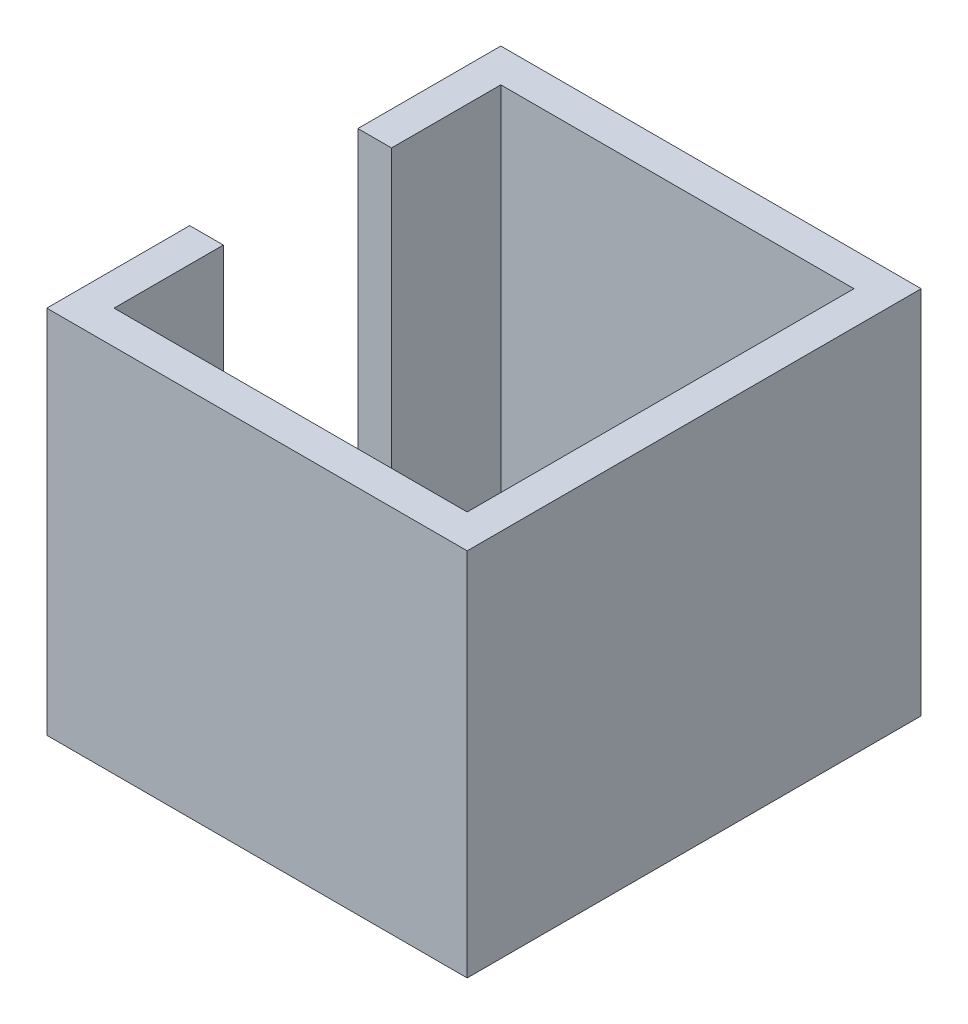
from build123d import *

# Parameters (mm, degrees)
SKETCH1_W           = 25
SKETCH1_H           = 27
SKETCH1_W_2         = 21
SKETCH1_H_2         = 23
BOSS_EXTRUDE1_DEPTH = 11
CUT_EXTRUDE1_START  = -10.5
SKETCH2_W           = 10
SKETCH2_H           = 17
CUT_EXTRUDE1_DEPTH  = 3


with BuildPart() as part:
    # Sketch1 → Boss-Extrude1 (new body, symmetric)
    with BuildSketch(Plane(origin=(0, 0, 0), x_dir=(1, 0, 0), z_dir=(0, 1, 0))):
        Rectangle(SKETCH1_W, SKETCH1_H)
        Rectangle(SKETCH1_W_2, SKETCH1_H_2, mode=Mode.SUBTRACT)
    extrude(amount=BOSS_EXTRUDE1_DEPTH, both=True)

    # Sketch2 → Cut-Extrude1 (cut)
    with BuildSketch(Plane(origin=(0, 0, 0), x_dir=(0, 0, -1), z_dir=(1, 0, 0)).offset(CUT_EXTRUDE1_START)):
        with Locations((0, 2.5)):
            Rectangle(SKETCH2_W, SKETCH2_H)
    extrude(amount=-CUT_EXTRUDE1_DEPTH, mode=Mode.SUBTRACT)


solid = part.part
